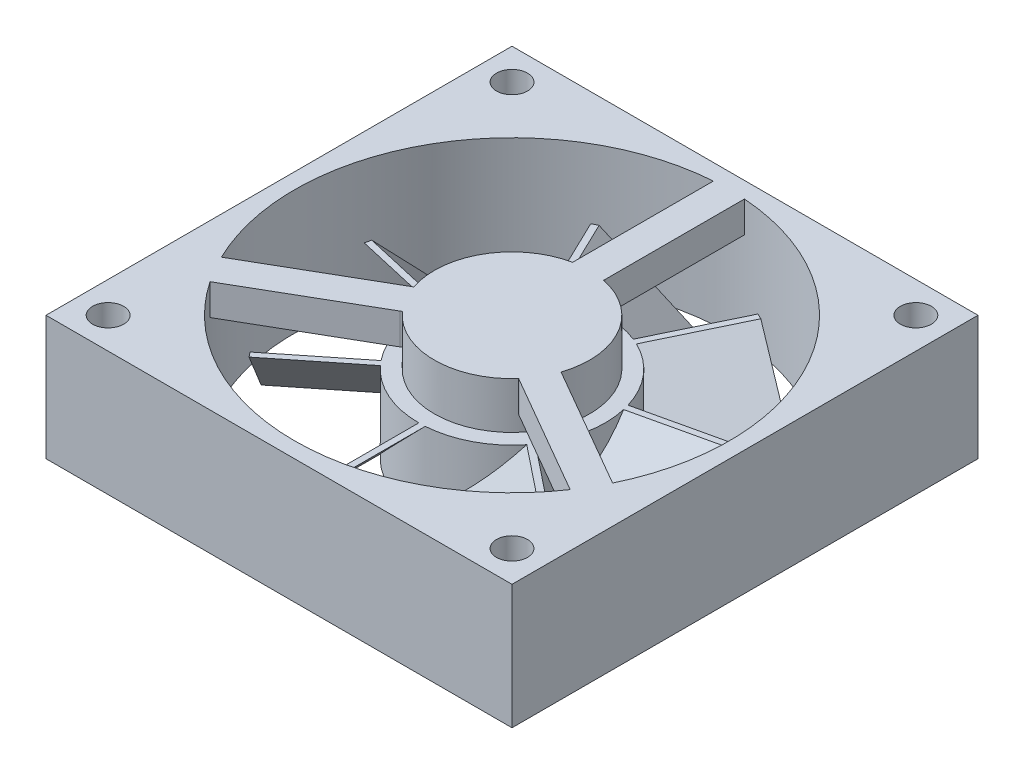
from build123d import *

# Parameters (mm, degrees)
SKETCH1_W                 = 30
SKETCH1_H                 = 30
SKETCH1_R                 = 14
BOSS_EXTRUDE1_DEPTH       = 8
SKETCH2_R                 = 5
BOSS_EXTRUDE2_DEPTH       = 8
BOSS_EXTRUDE3_DEPTH       = 2
F_2_0MM_DOWEL_HOLE1_D     = 2
F_2_0MM_DOWEL_HOLE1_DEPTH = 8
SKETCH7_R                 = 6
BOSS_EXTRUDE4_DEPTH       = 5
BOSS_EXTRUDE5_DEPTH       = 12
CIRPATTERN1_COUNT         = 7


with BuildPart() as part:
    # Sketch1 → Boss-Extrude1 (new body)
    with BuildSketch(Plane(origin=(0, 0, 0), x_dir=(1, 0, 0), z_dir=(0, 1, 0))):
        Rectangle(SKETCH1_W, SKETCH1_H)
        Circle(SKETCH1_R, mode=Mode.SUBTRACT)
    extrude(amount=BOSS_EXTRUDE1_DEPTH)



with BuildPart() as body_2:
    # Sketch2 → Boss-Extrude2 (new body)
    with BuildSketch(Plane(origin=(0, 0, 0), x_dir=(1, 0, 0), z_dir=(0, 1, 0))):
        Circle(SKETCH2_R)
    extrude(amount=BOSS_EXTRUDE2_DEPTH)


with BuildPart() as part_1:
    add(part.part)

    add(body_2.part)  # Boss-Extrude3 merges body 2
    # Sketch3 → Boss-Extrude3 (add)
    with BuildSketch(Plane(origin=(0, 8, 0), x_dir=(1, 0, 0), z_dir=(0, 1, 0))):
        with BuildLine():
            Line((-1, 5), (-1, 14))
            ThreePointArc((-1, 14), (0, 15), (1, 14))
            Line((1, 14), (1, 5))
            ThreePointArc((1, 5), (0, 4), (-1, 5))
        make_face()
        with BuildLine():
            Line((-3.830127019, -3.366025404), (-11.624355653, -7.866025404))
            ThreePointArc((-11.624355653, -7.866025404), (-12.990381057, -7.5), (-12.624355653, -6.133974596))
            Line((-12.624355653, -6.133974596), (-4.830127019, -1.633974596))
            ThreePointArc((-4.830127019, -1.633974596), (-3.464101615, -2), (-3.830127019, -3.366025404))
        make_face()
        with BuildLine():
            Line((4.830127019, -1.633974596), (12.624355653, -6.133974596))
            ThreePointArc((12.624355653, -6.133974596), (12.990381057, -7.5), (11.624355653, -7.866025404))
            Line((11.624355653, -7.866025404), (3.830127019, -3.366025404))
            ThreePointArc((3.830127019, -3.366025404), (3.464101615, -2), (4.830127019, -1.633974596))
        make_face()
    extrude(amount=-BOSS_EXTRUDE3_DEPTH)

    # Ø2.0mm Dowel Hole1
    with Locations(Plane(origin=(0, 8, 0), x_dir=(1, 0, 0), z_dir=(0, 1, 0))):
        with Locations((13, 13), (-13, 13), (-13, -13), (13, -13)):
            Hole(F_2_0MM_DOWEL_HOLE1_D / 2, depth=F_2_0MM_DOWEL_HOLE1_DEPTH)

    # Sketch7 → Boss-Extrude4 (add)
    with BuildSketch(Plane.XZ):
        Circle(SKETCH7_R)
    extrude(amount=-BOSS_EXTRUDE4_DEPTH)

    # Sketch9 → Boss-Extrude5 (add)
    with BuildSketch(Plane.XY):
        Polygon((0, 5), (-4.898979486, 0), (-4.498979486, 0), (0.4, 5), align=None)
    boss_extrude5 = extrude(amount=BOSS_EXTRUDE5_DEPTH)

    # CirPattern1: Boss-Extrude5 ×7 about axis
    cirpattern1_axis = Axis((0, 0, 0), (0, 1, 0))
    for i in range(1, CIRPATTERN1_COUNT):
        add(boss_extrude5.rotate(cirpattern1_axis, i * 360 / CIRPATTERN1_COUNT))


solid = part_1.part
